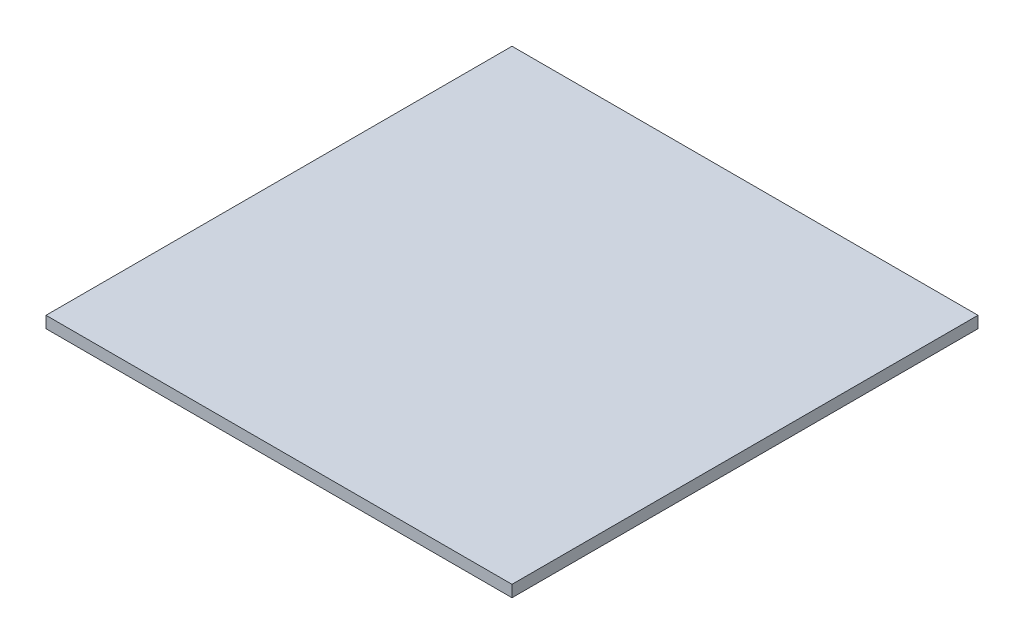
from build123d import *

# Parameters (mm, degrees)
ESQUISSE1_W      = 400
ESQUISSE1_H      = 400
EXTRUSION1_DEPTH = 10


with BuildPart() as part:
    # Esquisse1 → Extrusion1 (new body)
    with BuildSketch(Plane(origin=(0, 0, 0), x_dir=(1, 0, 0), z_dir=(0, 1, 0))):
        with Locations((200, 200)):
            Rectangle(ESQUISSE1_W, ESQUISSE1_H)
    extrude(amount=EXTRUSION1_DEPTH)


solid = part.part
